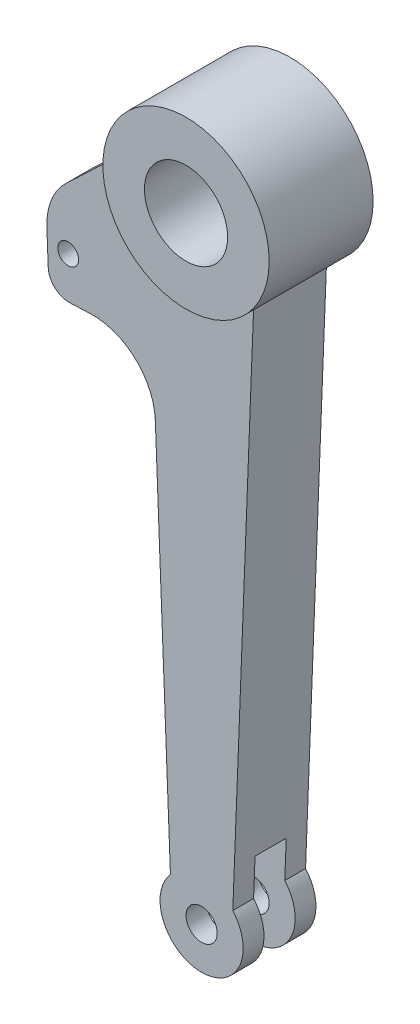
from build123d import *

# Parameters (mm, degrees)
SKETCH1_R           = 40
SKETCH1_R_2         = 20
BOSS_EXTRUDE1_DEPTH = 25
SKETCH3_R           = 7.5
BOSS_EXTRUDE3_DEPTH = 17.5
SKETCH5_R           = 35
CUT_EXTRUDE1_DEPTH  = 7.5
SKETCH6_W           = 12.5
SKETCH6_H           = 40
BOSS_EXTRUDE4_DEPTH = 50
SKETCH7_R           = 5
CUT_EXTRUDE2_DEPTH  = 43.5
BOSS_EXTRUDE5_DEPTH = 12.5
FILLET2_R           = 10
FILLET3_R           = 30
FILLET4_R           = 10
FILLET5_R           = 30


with BuildPart() as part:
    # Sketch1 → Boss-Extrude1 (new body, symmetric)
    with BuildSketch(Plane.XY):
        Circle(SKETCH1_R)
        Circle(SKETCH1_R_2, mode=Mode.SUBTRACT)
    extrude(amount=BOSS_EXTRUDE1_DEPTH, both=True)

    # Sketch3 → Boss-Extrude3 (add, symmetric)
    with BuildSketch(Plane.XY):
        with BuildLine():
            Line((-25, -31.224989992), (-15, -286.771243445))
            ThreePointArc((-15, -286.771243445), (0, -320), (15, -286.771243445))
            Line((15, -286.771243445), (25, -31.224989992))
            ThreePointArc((25, -31.224989992), (0, -40), (-25, -31.224989992))
        make_face()
        with Locations((0, -300)):
            Circle(SKETCH3_R, mode=Mode.SUBTRACT)
    extrude(amount=BOSS_EXTRUDE3_DEPTH, both=True)

    # Sketch5 → Cut-Extrude1 (cut, symmetric)
    with BuildSketch(Plane.XY):
        with Locations((0, -300)):
            Circle(SKETCH5_R)
    extrude(amount=CUT_EXTRUDE1_DEPTH, both=True, mode=Mode.SUBTRACT)

    # Sketch6 → Boss-Extrude4 (add)
    with BuildSketch(Plane(origin=(-26.181799658, -1.024542497, 0), x_dir=(0, 0, 1), z_dir=(-0.999235227, -0.039101932, 0))):
        with Locations((11.25, -50.223561659)):
            Rectangle(SKETCH6_W, SKETCH6_H)
        with Locations((-11.25, -50.223561659)):
            Rectangle(SKETCH6_W, SKETCH6_H)
    extrude(amount=BOSS_EXTRUDE4_DEPTH)

    # Sketch7 → Cut-Extrude2 (cut, through all)
    with BuildSketch(Plane(origin=(0, 0, -17.5), x_dir=(-1, 0, 0), z_dir=(0, 0, -1))):
        with Locations((64.187370437, -52.773771819)):
            Circle(SKETCH7_R)
    extrude(amount=-CUT_EXTRUDE2_DEPTH, mode=Mode.SUBTRACT)

    # Sketch8 → Boss-Extrude5 (add)
    with BuildSketch(Plane(origin=(0, 0, -17.5), x_dir=(-1, 0, 0), z_dir=(0, 0, -1))):
        with BuildLine():
            Line((74.961761351, -33.180086601), (40, 0))
            ThreePointArc((40, 0), (36.055512755, -17.320508076), (25, -31.224989992))
            Line((25, -31.224989992), (74.961761351, -33.180086601))
        make_face()
    boss_extrude5 = extrude(amount=-BOSS_EXTRUDE5_DEPTH)

    # Mirror2: Boss-Extrude5 across plane
    add(boss_extrude5.mirror(Plane.XY))

    # Fillet2
    fillet2_edges = [part.edges().sort_by_distance(p)[0] for p in [
        (-73.397684064, -73.149495681, 11.25),
        (-73.397684064, -73.149495681, -11.25),
    ]]
    fillet(fillet2_edges, radius=FILLET2_R)

    # Fillet3
    fillet3_edges = [part.edges().sort_by_distance(p)[0] for p in [
        (-23.435922713, -71.194399072, 11.25),
        (-23.435922713, -71.194399072, -11.25),
    ]]
    fillet(fillet3_edges, radius=FILLET3_R)

    # Fillet4
    fillet4_edges = [part.edges().sort_by_distance(p)[0] for p in [
        (-40, 0, -11.25),
        (-40, 0, 11.25),
    ]]
    fillet(fillet4_edges, radius=FILLET4_R)

    # Fillet5
    fillet5_edges = [part.edges().sort_by_distance(p)[0] for p in [
        (-74.961761351, -33.180086601, 11.25),
        (-74.961761351, -33.180086601, -11.25),
    ]]
    fillet(fillet5_edges, radius=FILLET5_R)


solid = part.part
